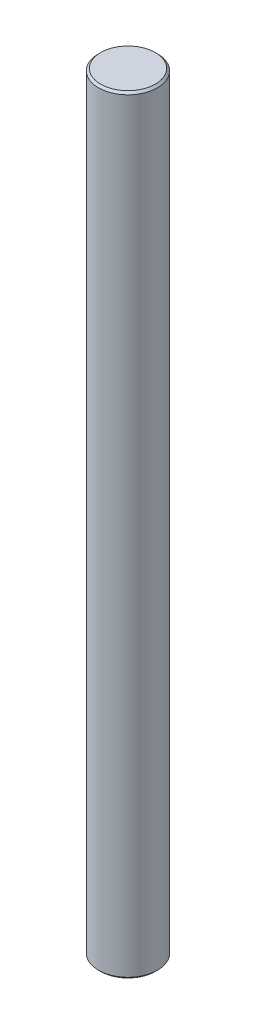
from build123d import *

# Parameters (mm, degrees)
SKETCH1_R           = 14
BOSS_EXTRUDE1_DEPTH = 182.5
CHAMFER1_SIZE       = 1


with BuildPart() as part:
    # Sketch1 → Boss-Extrude1 (new body, symmetric)
    with BuildSketch(Plane(origin=(0, 0, 0), x_dir=(1, 0, 0), z_dir=(0, 1, 0))):
        Circle(SKETCH1_R)
    extrude(amount=BOSS_EXTRUDE1_DEPTH, both=True)

    # Chamfer1
    chamfer1_edges = [part.edges().sort_by_distance(p)[0] for p in [
        (-14, -182.5, 0),
        (-14, 182.5, 0),
    ]]
    chamfer(chamfer1_edges, length=CHAMFER1_SIZE)


solid = part.part
